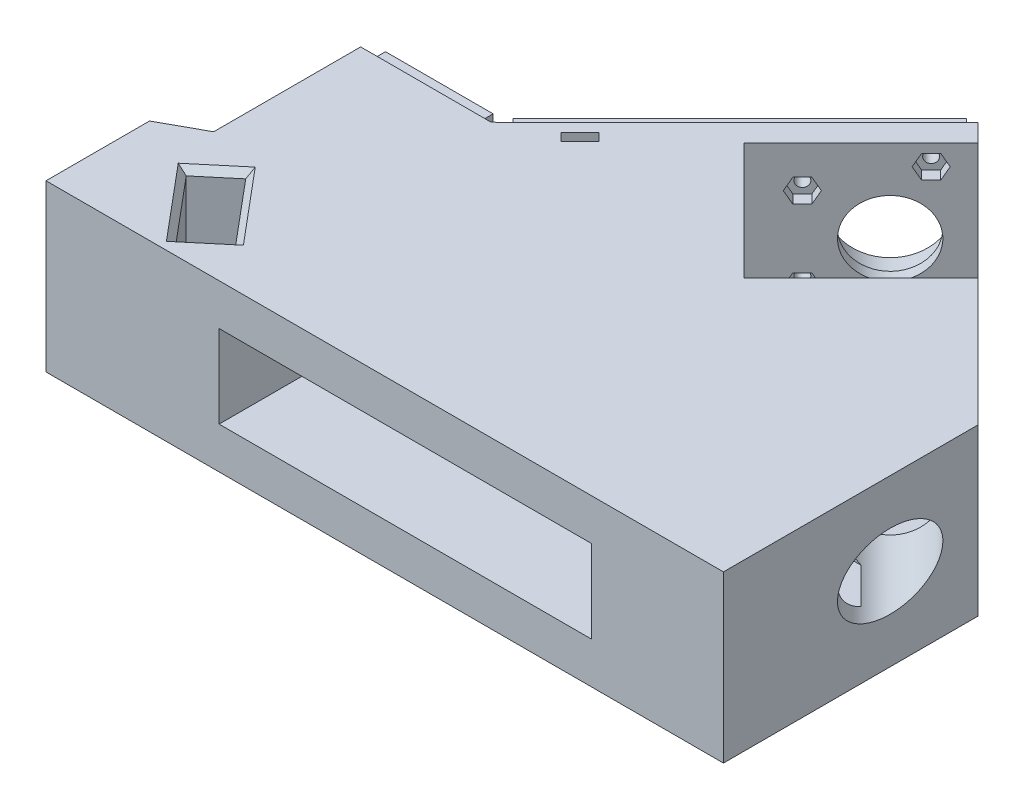
from build123d import *

# Parameters (mm, degrees)
BOSS_EXTRUDE1_DEPTH  = 40
SKETCH3_R            = 9
CUT_EXTRUDE1_DEPTH   = 135.350288425
SKETCH4_W            = 25
SKETCH4_H            = 30
CUT_EXTRUDE2_DEPTH   = 30
SKETCH5_R            = 11.1
CUT_EXTRUDE3_DEPTH   = 7
SKETCH6_R            = 11.1
CUT_EXTRUDE4_DEPTH   = 7
CUT_EXTRUDE5_DEPTH   = 41
SKETCH9_W            = 50
SKETCH9_H            = 40
BOSS_EXTRUDE2_DEPTH  = 30
SKETCH11_R           = 1.45
CUT_EXTRUDE8_DEPTH   = 20
SKETCH15_W           = 81.391173049
SKETCH15_H           = 40
SKETCH15_W_2         = 77.391173049
SKETCH15_H_2         = 36
CUT_EXTRUDE9_DEPTH   = 4
SKETCH16_W           = 30
SKETCH16_H           = 40
SKETCH16_W_2         = 26
SKETCH16_H_2         = 36
CUT_EXTRUDE10_DEPTH  = 4
CUT_EXTRUDE11_DEPTH  = 41
SKETCH18_W           = 153.620263659
SKETCH18_H           = 20
BOSS_EXTRUDE3_DEPTH  = 40
CUT_EXTRUDE7_DEPTH   = 41
SKETCH19_W           = 15
SKETCH19_H           = 15
CUT_EXTRUDE12_DEPTH  = 150
SKETCH20_R           = 1.45
CUT_EXTRUDE13_DEPTH  = 20
CUT_EXTRUDE16_DEPTH  = 3
CUT_EXTRUDE18_START  = -7
CUT_EXTRUDE18_DEPTH  = 2.55
SKETCH38_W           = 90
SKETCH38_H           = 20
CUT_EXTRUDE19_DEPTH  = 45.5
CUT_EXTRUDE21_START  = -31.810131
CUT_EXTRUDE21_DEPTH  = 90
BOSS_EXTRUDE11_DEPTH = 40
CHAMFER1_SIZE        = 1.5


with BuildPart() as part:
    # Sketch1 → Boss-Extrude1 (new body)
    with BuildSketch(Plane(origin=(0, 0, 0), x_dir=(1, 0, 0), z_dir=(0, 1, 0))):
        Polygon((-79.503540842, -54.434705768), (-79.503540842, -4.434705768), (-46.700027791, 28.368807283), (-21.951290449, 53.117544624), (-14.880222638, 46.046476813), (-43.164493885, 17.762205565), (-14.880222638, -10.522065682), (13.40404861, 17.762205565), (60.496459158, -29.330204983), (60.496459158, -54.434705768), align=None)
    extrude(amount=BOSS_EXTRUDE1_DEPTH)

    # Sketch3 → Cut-Extrude1 (cut, through all)
    with BuildSketch(Plane(origin=(-37.534417537, 0, -37.534417537), x_dir=(-0.707106781, 0, 0.707106781), z_dir=(-0.707106781, 0, -0.707106781))):
        with Locations((-7.037869671, 20)):
            Circle(SKETCH3_R)
    extrude(amount=-CUT_EXTRUDE1_DEPTH, mode=Mode.SUBTRACT)

    # Sketch4 → Cut-Extrude2 (cut)
    with BuildSketch(Plane(origin=(15.583127088, 0, -15.583127088), x_dir=(-0.707106781, 0, -0.707106781), z_dir=(0.707106781, 0, -0.707106781))):
        with Locations((-19.418317664, 20)):
            Rectangle(SKETCH4_W, SKETCH4_H)
    extrude(amount=-CUT_EXTRUDE2_DEPTH, mode=Mode.SUBTRACT)

    # Sketch5 → Cut-Extrude3 (cut)
    with BuildSketch(Plane(origin=(-37.534417537, 0, -37.534417537), x_dir=(-0.707106781, 0, 0.707106781), z_dir=(-0.707106781, 0, -0.707106781))):
        with Locations((-7.037869671, 20)):
            Circle(SKETCH5_R)
    extrude(amount=-CUT_EXTRUDE3_DEPTH, mode=Mode.SUBTRACT)

    # Sketch6 → Cut-Extrude4 (cut)
    with BuildSketch(Plane(origin=(4.891989334, 0, 4.891989334), x_dir=(0.707106781, 0, -0.707106781), z_dir=(0.707106781, 0, 0.707106781))):
        with Locations(Location((7.037869671, 20, 0), (0, 0, 180))):  # turned: the seam where the file's is
            Circle(SKETCH6_R)
    extrude(amount=-CUT_EXTRUDE4_DEPTH, mode=Mode.SUBTRACT)

    # Sketch7 → Cut-Extrude5 (cut, through all)
    with BuildSketch(Plane(origin=(0, 40, 0), x_dir=(1, 0, 0), z_dir=(0, 1, 0))):
        Polygon((44.116722817, -12.950468642), (44.116722817, -54.434705768), (60.496459158, -54.434705768), (60.496459158, -29.330204983), align=None)
    extrude(amount=-CUT_EXTRUDE5_DEPTH, mode=Mode.SUBTRACT)

    # Sketch9 → Boss-Extrude2 (add)
    with BuildSketch(Plane.ZY.offset(79.503540842)):
        with Locations((29.434705768, 20)):
            Rectangle(SKETCH9_W, SKETCH9_H)
    extrude(amount=BOSS_EXTRUDE2_DEPTH)

    # Sketch11 → Cut-Extrude8 (cut)
    with BuildSketch(Plane(origin=(-37.534417537, 0, -37.534417537), x_dir=(-0.707106781, 0, 0.707106781), z_dir=(-0.707106781, 0, -0.707106781))):
        with Locations((7.962130329, 10)):
            Circle(SKETCH11_R)
        with Locations((7.962130329, 30)):
            Circle(SKETCH11_R)
    extrude(amount=-CUT_EXTRUDE8_DEPTH, mode=Mode.SUBTRACT)

    # Sketch15 → Cut-Extrude9 (cut)
    with BuildSketch(Plane(origin=(-37.534417537, 0, -37.534417537), x_dir=(-0.707106781, 0, 0.707106781), z_dir=(-0.707106781, 0, -0.707106781))):
        with Locations((18.657716854, 20)):
            Rectangle(SKETCH15_W, SKETCH15_H)
        with Locations((18.657716854, 20)):
            Rectangle(SKETCH15_W_2, SKETCH15_H_2, mode=Mode.SUBTRACT)
    extrude(amount=-CUT_EXTRUDE9_DEPTH, mode=Mode.SUBTRACT)

    # Sketch16 → Cut-Extrude10 (cut)
    with BuildSketch(Plane(origin=(0, 0, 4.434705768), x_dir=(-1, 0, 0), z_dir=(0, 0, -1))):
        with Locations((94.503540842, 20)):
            Rectangle(SKETCH16_W, SKETCH16_H)
        with Locations((94.503540842, 20)):
            Rectangle(SKETCH16_W_2, SKETCH16_H_2, mode=Mode.SUBTRACT)
    extrude(amount=-CUT_EXTRUDE10_DEPTH, mode=Mode.SUBTRACT)

    # Sketch17 → Cut-Extrude11 (cut, through all)
    with BuildSketch(Plane.XZ):
        Polygon((-76.675113717, 7.263132892), (-78.089327279, 8.434705768), (-79.503540842, 8.434705768), (-79.503540842, 4.434705768), align=None)
    extrude(amount=-CUT_EXTRUDE11_DEPTH, mode=Mode.SUBTRACT)

    # Sketch18 → Boss-Extrude3 (add)
    with BuildSketch(Plane(origin=(0, 40, 0), x_dir=(1, 0, 0), z_dir=(0, 1, 0))):
        with Locations((-32.693409012, -64.434705768)):
            Rectangle(SKETCH18_W, SKETCH18_H)
    extrude(amount=-BOSS_EXTRUDE3_DEPTH)

    # Sketch10 → Cut-Extrude7 (cut, through all)
    with BuildSketch(Plane(origin=(0, 40, 0), x_dir=(1, 0, 0), z_dir=(0, 1, 0))):
        Polygon((-92.108080814, -70.449971453), (-105.09239053, -54.975873702), (-97.27873721, -48.419440083), (-84.294427494, -63.893537834), align=None)
    extrude(amount=-CUT_EXTRUDE7_DEPTH, mode=Mode.SUBTRACT)

    # Sketch19 → Cut-Extrude12 (cut)
    with BuildSketch(Plane.ZY.offset(109.503540842)):
        with Locations((36.434705768, 20)):
            Rectangle(SKETCH19_W, SKETCH19_H)
    extrude(amount=-CUT_EXTRUDE12_DEPTH, mode=Mode.SUBTRACT)

    # Sketch20 → Cut-Extrude13 (cut)
    with BuildSketch(Plane(origin=(-37.534417537, 0, -37.534417537), x_dir=(-0.707106781, 0, 0.707106781), z_dir=(-0.707106781, 0, -0.707106781))):
        with Locations((45.962130329, 5)):
            Circle(SKETCH20_R)
        with Locations((45.962130329, 35)):
            Circle(SKETCH20_R)
        with Locations((-14.037869671, 35)):
            Circle(SKETCH20_R)
        with Locations((-14.037869671, 5)):
            Circle(SKETCH20_R)
    extrude(amount=-CUT_EXTRUDE13_DEPTH, mode=Mode.SUBTRACT)

    # Sketch36 → Cut-Extrude16 (cut)
    with BuildSketch(Plane(origin=(-30.463349725, 0, -30.463349725), x_dir=(0.707106781, 0, -0.707106781), z_dir=(0.707106781, 0, 0.707106781))):
        Polygon((12.412869671, 37.814582562), (10.787869671, 35), (12.412869671, 32.185417438), (15.662869671, 32.185417438), (17.287869671, 35), (15.662869671, 37.814582562), align=None)
        Polygon((15.662869671, 7.814582562), (12.412869671, 7.814582562), (10.787869671, 5), (12.412869671, 2.185417438), (15.662869671, 2.185417438), (17.287869671, 5), align=None)
        Polygon((-6.337130329, 32.814582562), (-9.587130329, 32.814582562), (-11.212130329, 30), (-9.587130329, 27.185417438), (-6.337130329, 27.185417438), (-4.712130329, 30), align=None)
        Polygon((-6.337130329, 12.814582562), (-9.587130329, 12.814582562), (-11.212130329, 10), (-9.587130329, 7.185417438), (-6.337130329, 7.185417438), (-4.712130329, 10), align=None)
    extrude(amount=-CUT_EXTRUDE16_DEPTH, mode=Mode.SUBTRACT)

    # Sketch37 → Cut-Extrude18 (cut)
    with BuildSketch(Plane(origin=(-37.534417537, 0, -37.534417537), x_dir=(-0.707106781, 0, 0.707106781), z_dir=(-0.707106781, 0, -0.707106781)).offset(CUT_EXTRUDE18_START)):
        Polygon((49.212130329, 5), (49.212130329, 0), (42.712130329, 0), (42.712130329, 5), (44.337130329, 7.814582562), (47.587130329, 7.814582562), align=None)
        Polygon((42.712130329, 35), (44.337130329, 32.185417438), (47.587130329, 32.185417438), (49.212130329, 35), (49.212130329, 40), (42.712130329, 40), align=None)
    extrude(amount=-CUT_EXTRUDE18_DEPTH, mode=Mode.SUBTRACT)

    # Sketch38 → Cut-Extrude19 (cut)
    with BuildSketch(Plane.XY.offset(74.434705768)):
        with Locations((-32.693409012, 20)):
            Rectangle(SKETCH38_W, SKETCH38_H)
    extrude(amount=-CUT_EXTRUDE19_DEPTH, mode=Mode.SUBTRACT)

    # Sketch39 → Cut-Extrude21 (cut)
    with BuildSketch(Plane.ZY.offset(109.503540842).offset(CUT_EXTRUDE21_START)):
        Polygon((28.934705768, 10), (13.968076221, 20), (28.934705768, 30), align=None)
    extrude(amount=-CUT_EXTRUDE21_DEPTH, mode=Mode.SUBTRACT)

    # Sketch42 → Boss-Extrude11 (add)
    with BuildSketch(Plane(origin=(0, 40, 0), x_dir=(1, 0, 0), z_dir=(0, 1, 0))):
        Polygon((-109.503540842, -43.934705768), (-109.503540842, -74.434705768), (-119.503540842, -74.434705768), (-119.503540842, -49.434705768), align=None)
    extrude(amount=-BOSS_EXTRUDE11_DEPTH)

    # Chamfer1
    chamfer1_edges = [part.edges().sort_by_distance(p)[0] for p in [
        (-88.201254154, 0, 67.171754643),
        (-98.600235672, 0, 62.712922577),
        (-101.18556387, 0, 51.697656892),
        (-90.786582352, 0, 56.156488958),
        (-88.201254154, 40, 67.171754643),
        (-90.786582352, 40, 56.156488958),
        (-101.18556387, 40, 51.697656892),
        (-98.600235672, 40, 62.712922577),
    ]]
    chamfer(chamfer1_edges, length=CHAMFER1_SIZE)


solid = part.part
